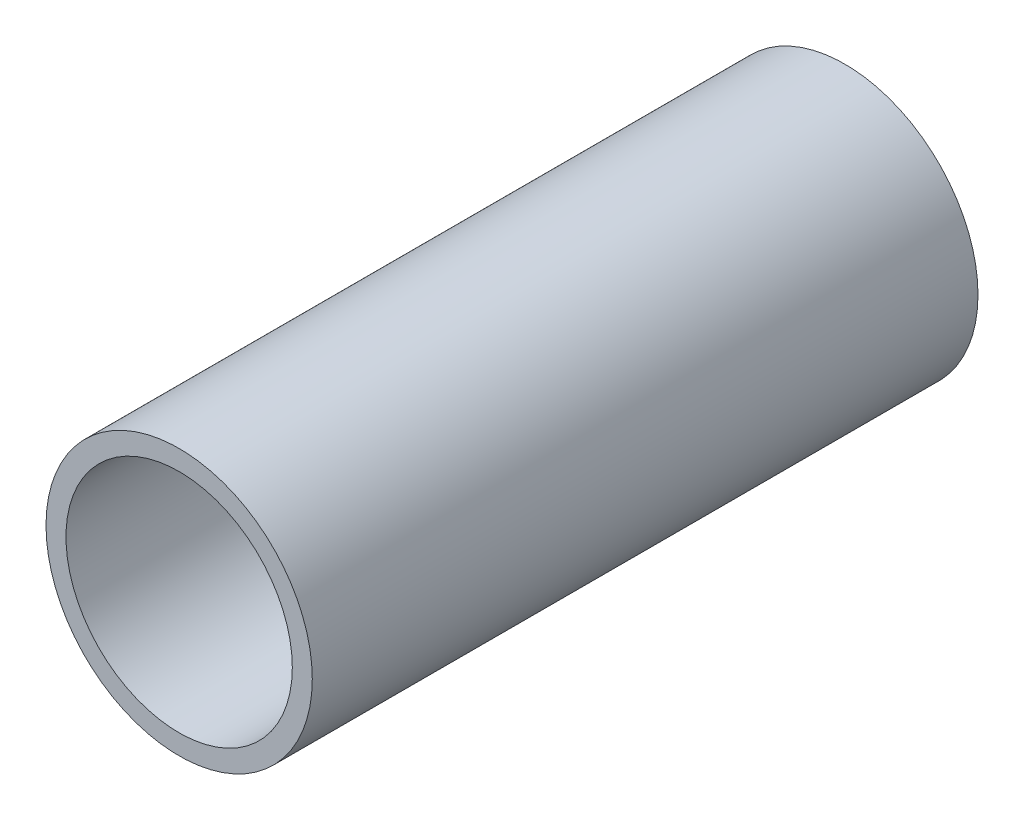
from build123d import *

# Parameters (mm, degrees)
SKETCH_1_R      = 20
SKETCH_1_R_2    = 17
EXTRUDE_1_DEPTH = 100


with BuildPart() as part:
    # Эскиз1 → Бобышка-Вытянуть1 (new body)
    with BuildSketch(Plane.XY):
        Circle(SKETCH_1_R)
        Circle(SKETCH_1_R_2, mode=Mode.SUBTRACT)
    extrude(amount=-EXTRUDE_1_DEPTH)


solid = part.part
